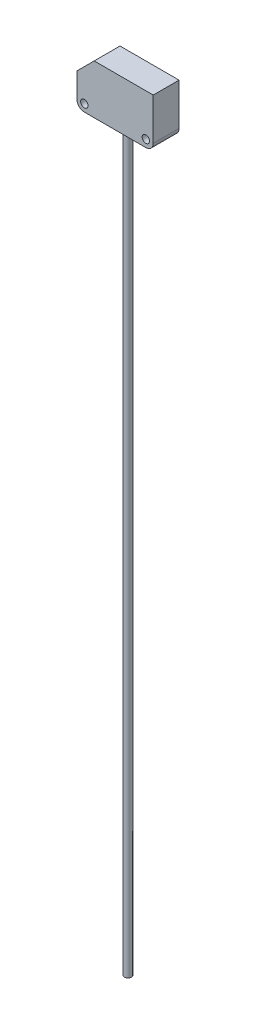
from build123d import *

# Parameters (mm, degrees)
BOSS_EXTRU_1_DEPTH      = 10.5
ESQUISSE2_R             = 1.5
ENL_V_MAT_EXTRU_1_DEPTH = 11.5
CONG_1_R                = 3
ESQUISSE3_W             = 18
ESQUISSE3_H             = 10.5
BOSS_EXTRU_2_DEPTH      = 0.01
ESQUISSE4_R             = 1.5
BOSS_EXTRU_3_DEPTH      = 300


with BuildPart() as part:
    # Esquisse1 → Boss.-Extru.1 (new body)
    with BuildSketch(Plane.XY):
        Polygon((0, 0), (31, 0), (31, 20), (7, 20), (0, 13), align=None)
    extrude(amount=-BOSS_EXTRU_1_DEPTH)

    # Esquisse2 → Enlèv. mat.-Extru.1 (cut, through all)
    with BuildSketch(Plane.XY):
        with Locations((3, 3)):
            Circle(ESQUISSE2_R)
        with Locations((28, 3)):
            Circle(ESQUISSE2_R)
    extrude(amount=-ENL_V_MAT_EXTRU_1_DEPTH, mode=Mode.SUBTRACT)

    # Congé1
    cong_1_edges = [part.edges().sort_by_distance(p)[0] for p in [
        (31, 0, -5.25),
        (0, 0, -5.25),
    ]]
    fillet(cong_1_edges, radius=CONG_1_R)

    # Esquisse3 → Boss.-Extru.2 (add)
    with BuildSketch(Plane.XZ):
        with Locations((15.5, -5.25)):
            Rectangle(ESQUISSE3_W, ESQUISSE3_H)
    extrude(amount=BOSS_EXTRU_2_DEPTH)

    # Esquisse4 → Boss.-Extru.3 (add)
    with BuildSketch(Plane.XZ.offset(0.01)):
        with Locations((15.5, -5.25)):
            Circle(ESQUISSE4_R)
    extrude(amount=BOSS_EXTRU_3_DEPTH)


solid = part.part
